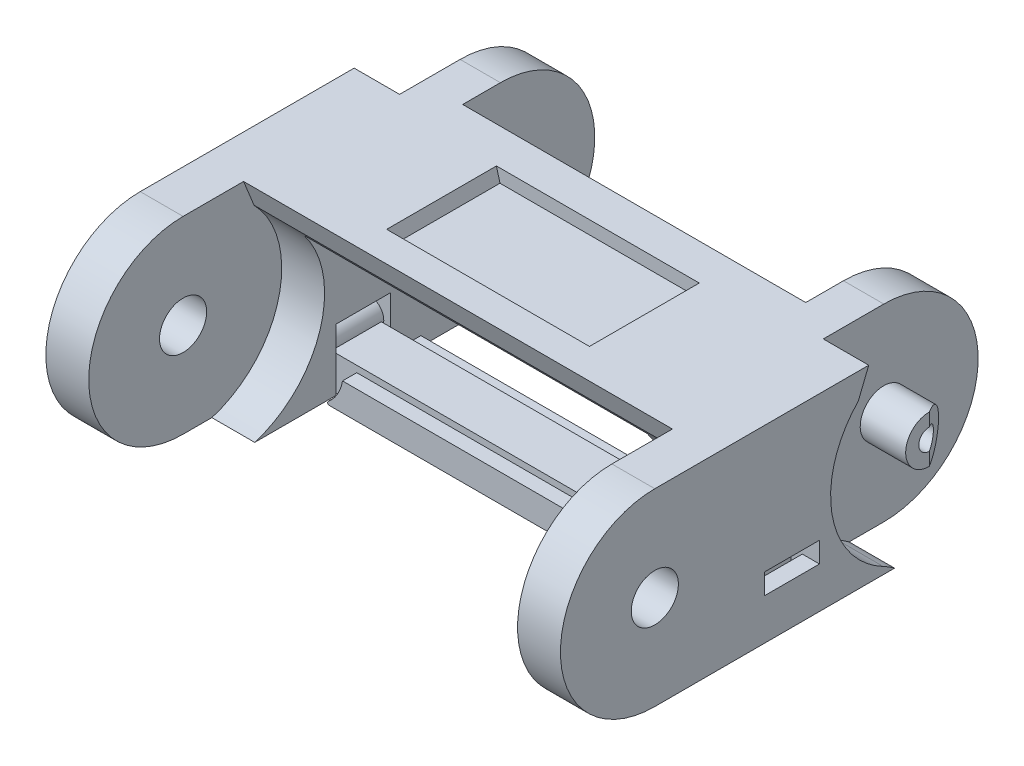
from build123d import *

# Parameters (mm, degrees)
SKETCH1_W                = 60
SKETCH1_H                = 22
BOSS_EXTRUDE1_DEPTH      = 54
CUT_EXTRUDE1_DEPTH       = 54
CUT_EXTRUDE1_DEPTH_BACK  = 54
SKETCH2_W                = 40
SKETCH2_H                = 18
CUT_EXTRUDE2_DEPTH       = 12.8
CUT_EXTRUDE3_DEPTH       = 54
CUT_EXTRUDE3_DEPTH_BACK  = 54
SKETCH4_W                = 120
SKETCH4_H                = 180
CUT_EXTRUDE4_DEPTH       = 30
CUT_EXTRUDE4_DEPTH_BACK  = 30
SKETCH5_W                = 96
SKETCH5_H                = 64
SKETCH6_R                = 2.75
CUT_EXTRUDE5_DEPTH       = 15
SKETCH7_R                = 1.222222222
CUT_EXTRUDE6_DEPTH       = 15
CUT_EXTRUDE7_DEPTH       = 30
CUT_EXTRUDE7_DEPTH_BACK  = 30
SKETCH8_R                = 2.75
CUT_EXTRUDE8_DEPTH       = 50
CUT_EXTRUDE9_START       = 15
SKETCH10_R               = 2.75
CUT_EXTRUDE9_DEPTH       = 15
CUT_EXTRUDE10_START      = 15
SKETCH11_R               = 1.222222222
CUT_EXTRUDE10_DEPTH      = 15
CUT_EXTRUDE11_DEPTH      = 3.2
CUT_EXTRUDE11_DEPTH_BACK = 3.2
SKETCH12_R               = 1.7
CUT_EXTRUDE12_DEPTH      = 3.2
CUT_EXTRUDE12_DEPTH_BACK = 3.2
SKETCH13_R               = 1.7
CUT_EXTRUDE13_DEPTH      = 2.75
CUT_EXTRUDE13_DEPTH_BACK = 2.75
CUT_EXTRUDE14_DEPTH      = 2.75
CUT_EXTRUDE14_DEPTH_BACK = 2.75
BOSS_EXTRUDE2_DEPTH      = 2.909090909
BOSS_EXTRUDE2_DEPTH_BACK = 2.909090909
BOSS_EXTRUDE3_DEPTH      = 4.571428571
BOSS_EXTRUDE3_DEPTH_BACK = 4.571428571


with BuildPart() as part:
    # Sketch1 → Boss-Extrude1 (new body)
    with BuildSketch(Plane.XY):
        Rectangle(SKETCH1_W, SKETCH1_H)
    extrude(amount=-BOSS_EXTRUDE1_DEPTH)

    # Sketch2 → Cut-Extrude1 (cut, two sides: drawn at the far end of the back side and taken through both)
    with BuildSketch(Plane.XY.offset(-CUT_EXTRUDE1_DEPTH_BACK)):
        with Locations((0, -2)):
            Rectangle(SKETCH2_W, SKETCH2_H)
    extrude(amount=CUT_EXTRUDE1_DEPTH + CUT_EXTRUDE1_DEPTH_BACK, mode=Mode.SUBTRACT)

    # Sketch3 → Cut-Extrude2 (cut)
    with BuildSketch(Plane.XY.offset(-21.56)):
        Polygon((-12, 11.66), (-11.410511777, 9.46), (11.410511777, 9.46), (12, 11.66), align=None)
    extrude(amount=-CUT_EXTRUDE2_DEPTH, mode=Mode.SUBTRACT)

    # Sketch4 → Cut-Extrude3 (cut, two sides: drawn at the far end of the back side and taken through both)
    with BuildSketch(Plane(origin=(0, 0, 0), x_dir=(-1, 0, 0), z_dir=(0, 1, 0)).offset(-CUT_EXTRUDE3_DEPTH_BACK)):
        with Locations((0, -30)):
            Rectangle(SKETCH4_W, SKETCH4_H)
        Polygon((30, -54), (30, 0), (20, 0), (20, -17.6), (-20, -17.6), (-20, 0), (-30, 0), (-30, -54), (-20, -54), (-20, -38.6), (20, -38.6), (20, -54), align=None, mode=Mode.SUBTRACT)
    extrude(amount=CUT_EXTRUDE3_DEPTH + CUT_EXTRUDE3_DEPTH_BACK, mode=Mode.SUBTRACT)

    # Sketch5 → Cut-Extrude4 (cut, two sides: drawn at the far end of the back side and taken through both)
    with BuildSketch(Plane(origin=(0, 0, 0), x_dir=(0, 0, -1), z_dir=(1, 0, 0)).offset(-CUT_EXTRUDE4_DEPTH_BACK)):
        with Locations((16, 0)):
            Rectangle(SKETCH5_W, SKETCH5_H)
        with BuildLine():
            Line((11, -11), (43, -11))
            ThreePointArc((43, -11), (54, 0), (43, 11))
            Line((43, 11), (11, 11))
            ThreePointArc((11, 11), (0, 0), (11, -11))
        make_face(mode=Mode.SUBTRACT)
    extrude(amount=CUT_EXTRUDE4_DEPTH + CUT_EXTRUDE4_DEPTH_BACK, mode=Mode.SUBTRACT)

    # Sketch6 → Cut-Extrude5 (cut)
    with BuildSketch(Plane(origin=(-24.7, 0, 0), x_dir=(0, 0, -1), z_dir=(1, 0, 0))):
        with BuildLine():
            Line((43, -11.5), (43, -38))
            Line((43, -38), (63.2, -38))
            Line((63.2, -38), (63.2, 41))
            Line((63.2, 41), (48.065075259, 41))
            Line((48.065075259, 41), (34.727592296, 7.98857126))
            ThreePointArc((34.727592296, 7.98857126), (32.414194185, -4.493407978), (43, -11.5))
        make_face()
        with Locations((43, 0)):
            Circle(SKETCH6_R, mode=Mode.SUBTRACT)
    extrude(amount=-CUT_EXTRUDE5_DEPTH, mode=Mode.SUBTRACT)

    # Sketch7 → Cut-Extrude6 (cut)
    with BuildSketch(Plane(origin=(-24.7, 0, 0), x_dir=(0, 0, -1), z_dir=(1, 0, 0))):
        with Locations((43, 0)):
            Circle(SKETCH7_R)
    extrude(amount=-CUT_EXTRUDE6_DEPTH, mode=Mode.SUBTRACT)

    # Sketch8 → Cut-Extrude7 (cut, two sides: drawn at the far end of the back side and taken through both)
    with BuildSketch(Plane(origin=(0, 0, 0), x_dir=(0, 0, -1), z_dir=(1, 0, 0)).offset(-CUT_EXTRUDE7_DEPTH_BACK)):
        with Locations((11, 0)):
            Circle(SKETCH8_R)
    extrude(amount=CUT_EXTRUDE7_DEPTH + CUT_EXTRUDE7_DEPTH_BACK, mode=Mode.SUBTRACT)

    # Sketch9 → Cut-Extrude8 (cut)
    with BuildSketch(Plane(origin=(-25, 0, 0), x_dir=(0, 0, -1), z_dir=(1, 0, 0))):
        with BuildLine():
            Line((-2.2, 26), (-2.2, -33))
            Line((-2.2, -33), (11, -33))
            Line((11, -33), (11, -11.5))
            ThreePointArc((11, -11.5), (21.585805815, -4.493407978), (19.272407704, 7.98857126))
            Line((19.272407704, 7.98857126), (11.995318128, 26))
            Line((11.995318128, 26), (-2.2, 26))
        make_face()
    extrude(amount=CUT_EXTRUDE8_DEPTH, mode=Mode.SUBTRACT)

    # Sketch10 → Cut-Extrude9 (cut)
    with BuildSketch(Plane(origin=(24.7, 0, 0), x_dir=(0, 0, -1), z_dir=(1, 0, 0)).offset(CUT_EXTRUDE9_START)):
        with BuildLine():
            Line((43, -19.032866311), (43, -38))
            Line((43, -38), (63.2, -38))
            Line((63.2, -38), (63.2, 41))
            Line((63.2, 41), (48.065075259, 41))
            Line((48.065075259, 41), (34.727592296, 7.98857126))
            ThreePointArc((34.727592296, 7.98857126), (31.646049671, -1.826967959), (37.651162791, -10.180370352))
            ThreePointArc((37.651162791, -10.180370352), (41.558961032, -13.861388181), (43, -19.032866311))
        make_face()
        with Locations((43, 0)):
            Circle(SKETCH10_R, mode=Mode.SUBTRACT)
    extrude(amount=-CUT_EXTRUDE9_DEPTH, mode=Mode.SUBTRACT)

    # Sketch11 → Cut-Extrude10 (cut)
    with BuildSketch(Plane(origin=(24.7, 0, 0), x_dir=(0, 0, -1), z_dir=(1, 0, 0)).offset(CUT_EXTRUDE10_START)):
        with Locations((43, 0)):
            Circle(SKETCH11_R)
    extrude(amount=-CUT_EXTRUDE10_DEPTH, mode=Mode.SUBTRACT)

    # Sketch12 → Cut-Extrude11 (cut, two sides: drawn at the far end of the back side and taken through both)
    with BuildSketch(Plane.XY.offset(-27).offset(-CUT_EXTRUDE11_DEPTH_BACK)):
        Polygon((-30, -6.2), (-28, -6.2), (-28, -11), (-20, -11), (-20, -3.8), (-30, -3.8), align=None)
        with Locations((-22.5, -7)):
            Circle(SKETCH12_R, mode=Mode.SUBTRACT)
    extrude(amount=CUT_EXTRUDE11_DEPTH + CUT_EXTRUDE11_DEPTH_BACK, mode=Mode.SUBTRACT)

    # Sketch13 → Cut-Extrude12 (cut, two sides: drawn at the far end of the back side and taken through both)
    with BuildSketch(Plane.XY.offset(-27).offset(-CUT_EXTRUDE12_DEPTH_BACK)):
        Polygon((20, -11), (28, -11), (28, -6.2), (30, -6.2), (30, -3.8), (20, -3.8), align=None)
        with Locations((22.5, -7)):
            Circle(SKETCH13_R, mode=Mode.SUBTRACT)
    extrude(amount=CUT_EXTRUDE12_DEPTH + CUT_EXTRUDE12_DEPTH_BACK, mode=Mode.SUBTRACT)

    # Sketch14 → Cut-Extrude13 (cut, two sides: drawn at the far end of the back side and taken through both)
    with BuildSketch(Plane(origin=(0, 0, 0), x_dir=(-1, 0, 0), z_dir=(0, 1, 0)).offset(-CUT_EXTRUDE13_DEPTH_BACK)):
        Polygon((-28.333333333, -45.75), (-30, -43), (-30, -45.75), align=None)
    extrude(amount=CUT_EXTRUDE13_DEPTH + CUT_EXTRUDE13_DEPTH_BACK, mode=Mode.SUBTRACT)

    # Sketch15 → Cut-Extrude14 (cut, two sides: drawn at the far end of the back side and taken through both)
    with BuildSketch(Plane(origin=(0, 0, 0), x_dir=(-1, 0, 0), z_dir=(0, 1, 0)).offset(-CUT_EXTRUDE14_DEPTH_BACK)):
        Polygon((30, -45.75), (30, -43), (28.333333333, -45.75), align=None)
    extrude(amount=CUT_EXTRUDE14_DEPTH + CUT_EXTRUDE14_DEPTH_BACK, mode=Mode.SUBTRACT)

    # Sketch16 → Boss-Extrude2 (add, two sides: drawn at the far end of the back side and taken through both)
    with BuildSketch(Plane.XY.offset(-27).offset(-BOSS_EXTRUDE2_DEPTH_BACK)):
        with BuildLine():
            Line((-23.4, -11), (23.4, -11))
            ThreePointArc((23.4, -11), (25.945584412, -9.945584412), (27, -7.4))
            Line((27, -7.4), (27, -5))
            Line((27, -5), (24.2, -5))
            Line((24.2, -5), (24.2, -7))
            ThreePointArc((24.2, -7), (22.5, -8.7), (20.8, -7))
            Line((20.8, -7), (-20.8, -7))
            ThreePointArc((-20.8, -7), (-22.5, -8.7), (-24.2, -7))
            Line((-24.2, -7), (-24.2, -5))
            Line((-24.2, -5), (-27, -5))
            Line((-27, -5), (-27, -7.4))
            ThreePointArc((-27, -7.4), (-25.945584412, -9.945584412), (-23.4, -11))
        make_face()
    extrude(amount=BOSS_EXTRUDE2_DEPTH + BOSS_EXTRUDE2_DEPTH_BACK)

    # Sketch17 → Boss-Extrude3 (add, two sides: drawn at the far end of the back side and taken through both)
    with BuildSketch(Plane.XY.offset(-27).offset(-BOSS_EXTRUDE3_DEPTH_BACK)):
        with BuildLine():
            Line((-19.379616013, -11), (19.379616013, -11))
            ThreePointArc((19.379616013, -11), (19.567915266, -10.867404682), (19.506538526, -10.645433911))
            ThreePointArc((19.506538526, -10.645433911), (18.409986139, -9.349848212), (17.843015997, -7.75))
            Line((17.843015997, -7.75), (-17.843015997, -7.75))
            ThreePointArc((-17.843015997, -7.75), (-18.409986139, -9.349848212), (-19.506538526, -10.645433911))
            ThreePointArc((-19.506538526, -10.645433911), (-19.567915266, -10.867404682), (-19.379616013, -11))
        make_face()
    extrude(amount=BOSS_EXTRUDE3_DEPTH + BOSS_EXTRUDE3_DEPTH_BACK)


solid = part.part
